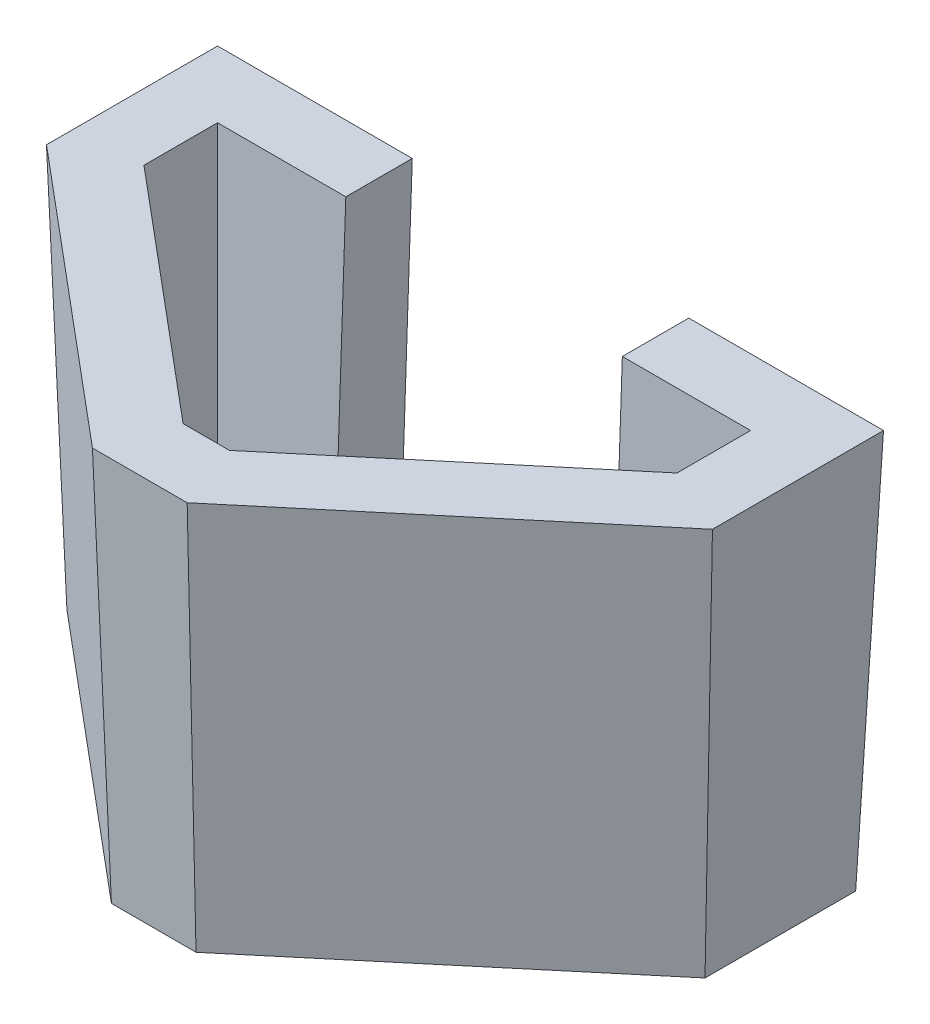
from build123d import *

# Parameters (mm, degrees)
SALIENTE_EXTRUIR1_DEPTH = 75
SALIENTE_EXTRUIR1_TAPER = -2
CORTAR_EXTRUIR1_DEPTH   = 76.0000001
CORTAR_EXTRUIR1_TAPER   = 2
CROQUIS5_W              = 52
CROQUIS5_H              = 12.5
CORTAR_EXTRUIR2_DEPTH   = 76.046325467


with BuildPart() as part:
    # Croquis2 → Saliente-Extruir1 (new body)
    with BuildSketch(Plane(origin=(0, 0, 0), x_dir=(1, 0, 0), z_dir=(0, 1, 0))):
        Polygon((-12.5, 12.5), (-12.5, -15.828845727), (39.545254998, -59.5), (55.454745002, -59.5), (107.5, -15.828845727), (107.5, 12.5), align=None)
    extrude(amount=SALIENTE_EXTRUIR1_DEPTH, taper=SALIENTE_EXTRUIR1_TAPER)

    # Croquis3 → Cortar-Extruir1 (cut, through all)
    with BuildSketch(Plane(origin=(0, 75, 0), x_dir=(1, 0, 0), z_dir=(0, 1, 0))):
        Polygon((-2.619057712, 2.619057712), (-2.619057712, -11.221286668), (43.141623877, -49.619057712), (51.858376123, -49.619057712), (97.619057712, -11.221286668), (97.619057712, 2.619057712), align=None)
    extrude(amount=-CORTAR_EXTRUIR1_DEPTH, taper=CORTAR_EXTRUIR1_TAPER, mode=Mode.SUBTRACT)

    # Croquis5 → Cortar-Extruir2 (cut, through all, along a direction that is not the sketch's normal)
    with BuildSketch(Plane.XZ):
        with Locations((47.5, -6.25)):
            Rectangle(CROQUIS5_W, CROQUIS5_H)
    extrude(amount=-CORTAR_EXTRUIR2_DEPTH, dir=(0, -0.999390827, 0.034899497), mode=Mode.SUBTRACT)


solid = part.part
